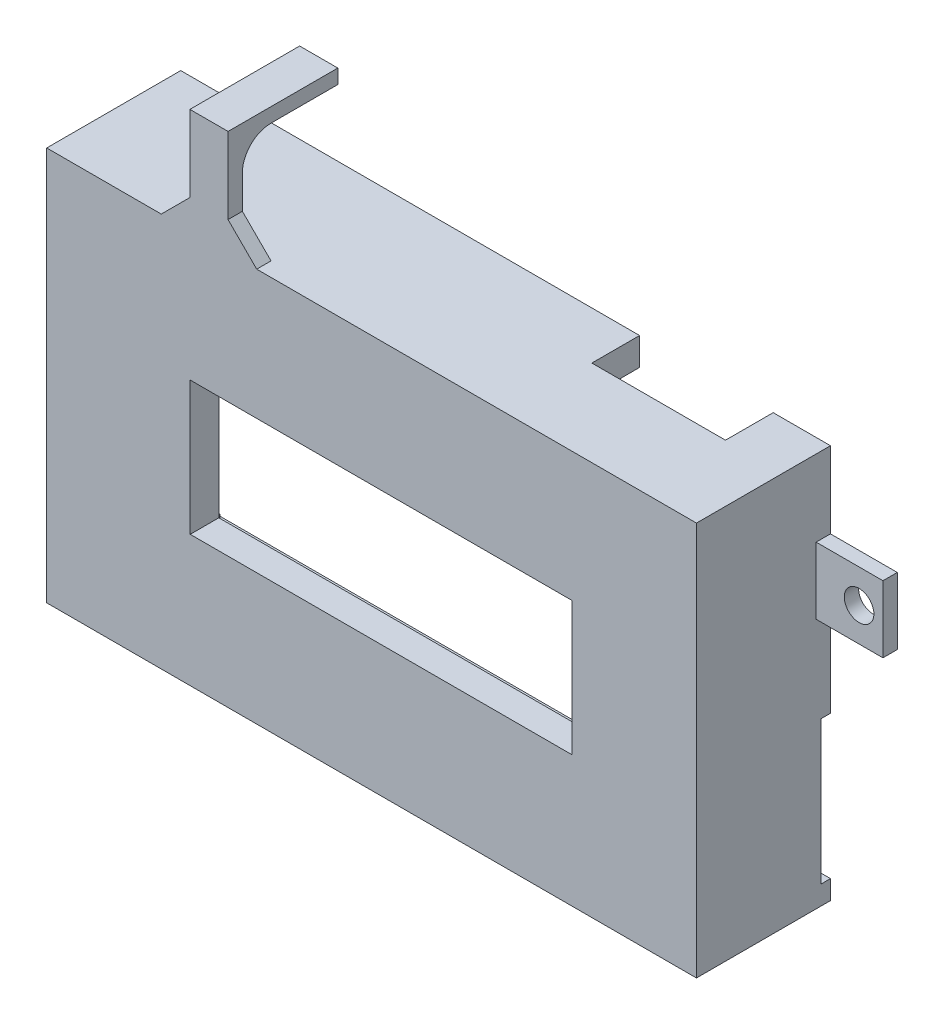
from build123d import *

# Parameters (mm, degrees)
SKETCH_1_W          = 68.077724156
SKETCH_1_H          = 41.280670561
SKETCH_1_W_2        = 40
SKETCH_1_H_2        = 14
EXTRUDE_1_DEPTH     = 3
SKETCH_2_W          = 68.077724156
SKETCH_2_H          = 41.280670561
SKETCH_2_W_2        = 62.677724156
SKETCH_2_H_2        = 35.480670561
EXTRUDE_2_DEPTH     = 11.04005
SKETCH_3_W          = 7.040050383
SKETCH_3_H          = 11.280670561
CUT_EXTRUDE_1_DEPTH = 2.9
SKETCH_4_W          = 3
SKETCH_4_H          = 1.8
EXTRUDE_3_DEPTH     = 3
SKETCH_5_W          = 3
SKETCH_5_H          = 1.8
EXTRUDE_4_DEPTH     = 3
SKETCH_6_W          = 3
SKETCH_6_H          = 1.8
EXTRUDE_5_DEPTH     = 2
SKETCH_7_W          = 3
SKETCH_7_H          = 1.8
EXTRUDE_6_DEPTH     = 2
SKETCH_8_W          = 14
SKETCH_8_H          = 5
CUT_EXTRUDE_2_DEPTH = 2.9
SKETCH_9_W          = 1
SKETCH_9_H          = 15
CUT_EXTRUDE_3_DEPTH = 1
SKETCH_10_W         = 1.5
SKETCH_10_H         = 7
EXTRUDE_7_DEPTH     = 7
SKETCH_13_R         = 1.55
CUT_EXTRUDE_6_DEPTH = 2.5
SKETCH_14_W         = 4
SKETCH_14_H         = 1.5
EXTRUDE_8_DEPTH     = 11
SKETCH_15_W         = 4
SKETCH_15_H         = 1.5
EXTRUDE_9_DEPTH     = 10
CHAMFER_1_SIZE      = 3
FILLET_2_R          = 3
SKETCH_16_W         = 7
SKETCH_16_H         = 1.5
EXTRUDE_10_DEPTH    = 7
SKETCH_17_R         = 1.55
CUT_EXTRUDE_7_DEPTH = 2.5


with BuildPart() as part:
    # 草图1 → 凸台-拉伸1 (new body)
    with BuildSketch(Plane.XY):
        with Locations((18.003533133, 5.902999581)):
            Rectangle(SKETCH_1_W, SKETCH_1_H)
        with Locations((19, 6)):
            Rectangle(SKETCH_1_W_2, SKETCH_1_H_2, mode=Mode.SUBTRACT)
    extrude(amount=-EXTRUDE_1_DEPTH)

    # 草图2 → 凸台-拉伸2 (add)
    with BuildSketch(Plane(origin=(0, 0, -3), x_dir=(-1, 0, 0), z_dir=(0, 0, -1))):
        with Locations((-18.003533133, 5.902999581)):
            Rectangle(SKETCH_2_W, SKETCH_2_H)
        with Locations((-18.203533133, 5.902999581)):
            Rectangle(SKETCH_2_W_2, SKETCH_2_H_2, mode=Mode.SUBTRACT)
    extrude(amount=EXTRUDE_2_DEPTH)

    # 草图3 → 切除-拉伸1 (cut)
    with BuildSketch(Plane.ZY.offset(16.035328945)):
        with Locations((-10.520025192, 5.902999581)):
            Rectangle(SKETCH_3_W, SKETCH_3_H)
    extrude(amount=-CUT_EXTRUDE_1_DEPTH, mode=Mode.SUBTRACT)

    # 草图4 → 凸台-拉伸3 (add)
    with BuildSketch(Plane.XZ.offset(-23.643334861)):
        with Locations((48.042395211, -11.340050383)):
            Rectangle(SKETCH_4_W, SKETCH_4_H)
    extrude(amount=EXTRUDE_3_DEPTH)

    # 草图5 → 凸台-拉伸4 (add)
    with BuildSketch(Plane(origin=(0, -11.8373357, 0), x_dir=(1, 0, 0), z_dir=(0, 1, 0))):
        with Locations((48.042395211, 11.340050383)):
            Rectangle(SKETCH_5_W, SKETCH_5_H)
    extrude(amount=EXTRUDE_4_DEPTH)

    # 草图6 → 凸台-拉伸5 (add)
    with BuildSketch(Plane.XZ.offset(-23.643334861)):
        with Locations((-11.635328945, -11.340050383)):
            Rectangle(SKETCH_6_W, SKETCH_6_H)
    extrude(amount=EXTRUDE_5_DEPTH)

    # 草图7 → 凸台-拉伸6 (add)
    with BuildSketch(Plane(origin=(0, -11.8373357, 0), x_dir=(1, 0, 0), z_dir=(0, 1, 0))):
        with Locations((-11.635328945, 11.340050383)):
            Rectangle(SKETCH_7_W, SKETCH_7_H)
    extrude(amount=EXTRUDE_6_DEPTH)

    # 草图8 → 切除-拉伸2 (cut)
    with BuildSketch(Plane(origin=(0, 26.543334861, 0), x_dir=(1, 0, 0), z_dir=(0, 1, 0))):
        with Locations((39.042395211, 11.540050383)):
            Rectangle(SKETCH_8_W, SKETCH_8_H)
    extrude(amount=-CUT_EXTRUDE_2_DEPTH, mode=Mode.SUBTRACT)

    # 草图9 → 切除-拉伸3 (cut)
    with BuildSketch(Plane(origin=(52.042395211, 0, 0), x_dir=(0, 0, -1), z_dir=(1, 0, 0))):
        with Locations((13.540050383, -5.2373357)):
            Rectangle(SKETCH_9_W, SKETCH_9_H)
    extrude(amount=-CUT_EXTRUDE_3_DEPTH, mode=Mode.SUBTRACT)

    # 草图10 → 凸台-拉伸7 (add)
    with BuildSketch(Plane(origin=(52.042395211, 0, 0), x_dir=(0, 0, -1), z_dir=(1, 0, 0))):
        with Locations((13.290050383, 15.043334861)):
            Rectangle(SKETCH_10_W, SKETCH_10_H)
    extrude(amount=EXTRUDE_7_DEPTH)

    # 草图13 → 切除-拉伸6 (cut, through all)
    with BuildSketch(Plane.XY.offset(-12.540050383)):
        with Locations((56.542395211, 15.043334861)):
            Circle(SKETCH_13_R)
    extrude(amount=-CUT_EXTRUDE_6_DEPTH, mode=Mode.SUBTRACT)

    # 草图14 → 凸台-拉伸8 (add)
    with BuildSketch(Plane(origin=(0, 26.543334861, 0), x_dir=(1, 0, 0), z_dir=(0, 1, 0))):
        with Locations((0.964671055, 0.75)):
            Rectangle(SKETCH_14_W, SKETCH_14_H)
    extrude(amount=EXTRUDE_8_DEPTH)

    # 草图15 → 凸台-拉伸9 (add)
    with BuildSketch(Plane(origin=(0, 0, -1.5), x_dir=(-1, 0, 0), z_dir=(0, 0, -1))):
        with Locations((-0.964671055, 36.793334861)):
            Rectangle(SKETCH_15_W, SKETCH_15_H)
    extrude(amount=EXTRUDE_9_DEPTH)

    # 倒角1
    chamfer_1_edges = [part.edges().sort_by_distance(p)[0] for p in [
        (2.964671055, 26.543334861, -0.75),
        (-1.035328945, 26.543334861, -0.75),
    ]]
    chamfer(chamfer_1_edges, length=CHAMFER_1_SIZE)

    # 圆角2
    fillet_2_edges = [part.edges().sort_by_distance(p)[0] for p in [
        (0.964671055, 36.043334861, -1.5),
    ]]
    fillet(fillet_2_edges, radius=FILLET_2_R)

    # 草图16 → 凸台-拉伸10 (add)
    with BuildSketch(Plane.XZ.offset(14.7373357)):
        with Locations((17.464671055, -13.290050383)):
            Rectangle(SKETCH_16_W, SKETCH_16_H)
    extrude(amount=EXTRUDE_10_DEPTH)

    # 草图17 → 切除-拉伸7 (cut, through all)
    with BuildSketch(Plane.XY.offset(-12.540050383)):
        with Locations((17.464671055, -19.2373357)):
            Circle(SKETCH_17_R)
    extrude(amount=-CUT_EXTRUDE_7_DEPTH, mode=Mode.SUBTRACT)


solid = part.part
